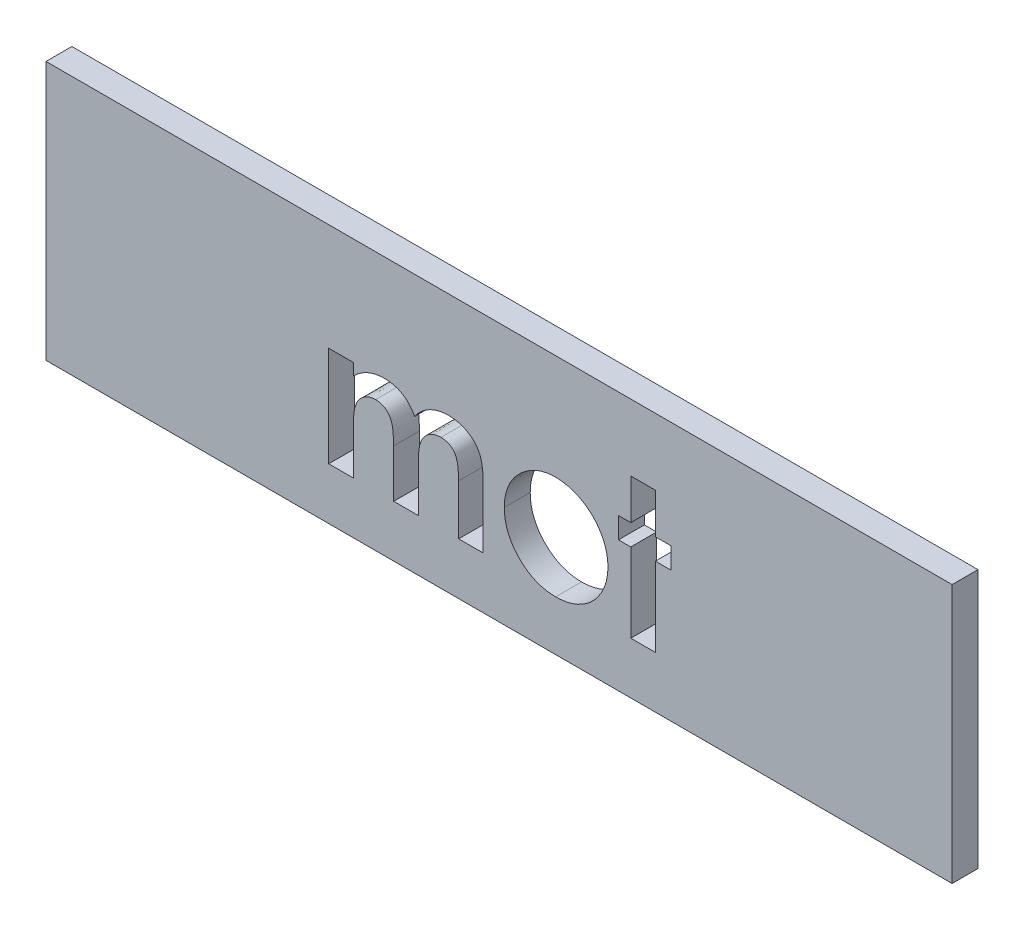
from build123d import *

# Parameters (mm, degrees)
ESQUISSE1_W             = 35
ESQUISSE1_H             = 10
BOSS_EXTRU_1_DEPTH      = 1
ESQUISSE2_R             = 1
BOSS_EXTRU_2_DEPTH      = 3
CHANFREIN1_SIZE         = 0.5
ENL_V_MAT_EXTRU_2_DEPTH = 1


with BuildPart() as part:
    # Esquisse1 → Boss.-Extru.1 (new body)
    with BuildSketch(Plane.XY):
        with Locations((17.5, -5)):
            Rectangle(ESQUISSE1_W, ESQUISSE1_H)
    extrude(amount=BOSS_EXTRU_1_DEPTH)

    # Esquisse2 → Boss.-Extru.2 (add)
    with BuildSketch(Plane(origin=(0, 0, 0), x_dir=(-1, 0, 0), z_dir=(0, 0, -1))):
        with Locations(Location((-30, -5, 0), (0, 0, 180))):  # turned: the seam where the file's is
            Circle(ESQUISSE2_R)
        with Locations(Location((-5, -5, 0), (0, 0, 180))):  # turned: the seam where the file's is
            Circle(ESQUISSE2_R)
    extrude(amount=BOSS_EXTRU_2_DEPTH)

    # Chanfrein1
    chanfrein1_edges = [part.edges().sort_by_distance(p)[0] for p in [
        (29, -5, -3),
        (4, -5, -3),
    ]]
    chamfer(chanfrein1_edges, length=CHANFREIN1_SIZE)

    # Esquisse3 → Enlèv. mat.-Extru.2 (cut)
    with BuildSketch(Plane.XY.offset(1)):
        with BuildLine():
            Line((10.919337607, -4.133012821), (11.869123932, -4.133012821))
            Line((11.869123932, -4.133012821), (11.869123932, -4.59518563))
            add(Edge.make_bspline(
                [(11.869123932, -4.59518563), (11.911369945, -4.552547263), (11.994548872, -4.468595821), (12.132392627, -4.360668696), (12.276177621, -4.268377671), (12.4276463, -4.193662277), (12.586428178, -4.136611678), (12.751770713, -4.09480584), (12.924523171, -4.070141705), (13.042144246, -4.066846229), (13.101938101, -4.06517094)],
                knots=[0, 0, 0, 0, 1.041528618, 2.050684245, 3.032913108, 4.004406485, 4.976926473, 5.95771665, 6.961784757, 8, 8, 8, 8], degree=3))
            add(Edge.make_bspline(
                [(13.101938101, -4.06517094), (13.161810904, -4.067054206), (13.279668581, -4.070761355), (13.451622112, -4.104685241), (13.614520608, -4.159800091), (13.766571805, -4.238359539), (13.908874639, -4.335376374), (14.035125, -4.45586279), (14.148765497, -4.595022486), (14.209340256, -4.700228713), (14.240409655, -4.754190037)],
                knots=[0, 0, 0, 0, 1.023965777, 2.015643508, 2.987309376, 3.958410333, 4.93654923, 5.924956801, 6.93568961, 8, 8, 8, 8], degree=3))
            add(Edge.make_bspline(
                [(14.240409655, -4.754190037), (14.280431057, -4.700081917), (14.358981836, -4.593882862), (14.498220248, -4.455227954), (14.648778513, -4.33536381), (14.813569588, -4.237643293), (14.988217192, -4.160068241), (15.171957089, -4.104890023), (15.363123432, -4.070818051), (15.493222619, -4.067068949), (15.559086205, -4.06517094)],
                knots=[0, 0, 0, 0, 1.041189987, 2.043563759, 3.033412161, 4.015238574, 5.00275396, 5.986226558, 6.980513695, 8, 8, 8, 8], degree=3))
            add(Edge.make_bspline(
                [(15.559086205, -4.06517094), (15.627115467, -4.067141729), (15.759596132, -4.070979658), (15.95157964, -4.108738156), (16.131395426, -4.167080701), (16.295069614, -4.251983383), (16.443069016, -4.352553973), (16.569182361, -4.471382321), (16.673844914, -4.604321999), (16.741993657, -4.728455222), (16.786049989, -4.838203205), (16.812651593, -4.933704514), (16.837532324, -5.040343805), (16.855406639, -5.159554459), (16.872091524, -5.290215988), (16.881777755, -5.433197075), (16.888361587, -5.588016049), (16.889060874, -5.695134454), (16.889423077, -5.750617655)],
                knots=[0, 0, 0, 0, 1.321991808, 2.574456155, 3.791773975, 4.987670122, 6.148905103, 7.262530793, 8.344737981, 9.427709016, 10.004683293, 10.642050061, 11.354108788, 12.133887687, 12.985666279, 13.916212488, 14.92067847, 16, 16, 16, 16], degree=3))
            Line((16.889423077, -5.750617655), (16.889423077, -8))
            Line((16.889423077, -8), (15.939636752, -8))
            Line((15.939636752, -8), (15.939636752, -6.058026175))
            add(Edge.make_bspline(
                [(15.939636752, -6.058026175), (15.938846235, -6.006081985), (15.937328909, -5.906379806), (15.93087817, -5.763376066), (15.916438656, -5.633684014), (15.899513696, -5.516585277), (15.875293753, -5.412700728), (15.845761929, -5.321779938), (15.811505193, -5.243692031), (15.770141216, -5.178445146), (15.723813514, -5.123496962), (15.672280628, -5.076395486), (15.616079868, -5.036208607), (15.554701692, -5.001955004), (15.486538148, -4.978788614), (15.41389033, -4.960611438), (15.336189747, -4.948232651), (15.282467581, -4.947494664), (15.254857772, -4.947115385)],
                knots=[0, 0, 0, 0, 1.669139205, 3.203761885, 4.596586177, 5.860166715, 7.002923539, 8.018877315, 8.928339525, 9.734594377, 10.491888885, 11.231098709, 11.971440889, 12.708030942, 13.480072485, 14.275788656, 15.113863979, 16, 16, 16, 16], degree=3))
            add(Edge.make_bspline(
                [(15.254857772, -4.947115385), (15.212311448, -4.948586321), (15.128822752, -4.951472742), (15.007162706, -4.979055723), (14.892679706, -5.024150945), (14.785802653, -5.085499), (14.688831303, -5.162121562), (14.60400592, -5.253003227), (14.533951983, -5.358667753), (14.48545894, -5.456703237), (14.455156879, -5.545347015), (14.43378153, -5.621263291), (14.417120294, -5.707113371), (14.404079425, -5.802027791), (14.391568234, -5.906543112), (14.385430314, -6.02052717), (14.379149348, -6.143821616), (14.379231113, -6.229033939), (14.379273504, -6.273212139)],
                knots=[0, 0, 0, 0, 1.129913425, 2.217230253, 3.297175357, 4.391411011, 5.481605898, 6.571841268, 7.681894157, 8.841607612, 9.468549532, 10.170608623, 10.93710061, 11.791434153, 12.717934886, 13.734733707, 14.825576123, 16, 16, 16, 16], degree=3))
            Line((14.379273504, -6.273212139), (14.379273504, -8))
            Line((14.379273504, -8), (13.429487179, -8))
            Line((13.429487179, -8), (13.429487179, -6.146008614))
            add(Edge.make_bspline(
                [(13.429487179, -6.146008614), (13.429407435, -6.104662165), (13.429254033, -6.02512499), (13.424643067, -5.910271787), (13.418537248, -5.804220605), (13.409977599, -5.706675648), (13.400105731, -5.617758237), (13.38585835, -5.537954814), (13.370890161, -5.466825637), (13.345227, -5.386025014), (13.309064305, -5.296484401), (13.25503671, -5.201531568), (13.18970997, -5.122030947), (13.114735212, -5.057363855), (13.030010519, -5.00809272), (12.93768223, -4.971441119), (12.835987395, -4.95165771), (12.76598747, -4.948661445), (12.729867788, -4.947115385)],
                knots=[0, 0, 0, 0, 1.256487322, 2.417074606, 3.49288742, 4.484586665, 5.393016842, 6.210437544, 6.947749329, 7.599905853, 8.784490193, 9.876739139, 10.906602197, 11.896672079, 12.869113195, 13.872201355, 14.902064413, 16, 16, 16, 16], degree=3))
            add(Edge.make_bspline(
                [(12.729867788, -4.947115385), (12.689055656, -4.948500619), (12.608226888, -4.951244088), (12.490487438, -4.980711182), (12.377917606, -5.024978991), (12.272993811, -5.088038137), (12.177483341, -5.166463861), (12.09350724, -5.259930578), (12.023821463, -5.36832742), (11.975113169, -5.469067075), (11.945252948, -5.559922392), (11.923302846, -5.637809906), (11.907261515, -5.725550598), (11.893877502, -5.822159294), (11.881440381, -5.927750032), (11.875277064, -6.042787158), (11.869002305, -6.167143162), (11.869082412, -6.253061473), (11.869123932, -6.297592815)],
                knots=[0, 0, 0, 0, 1.07893236, 2.136834559, 3.195274846, 4.273923004, 5.364443877, 6.458052972, 7.587287137, 8.767908, 9.410170275, 10.118584836, 10.909717261, 11.770069756, 12.702352573, 13.724628867, 14.820678298, 16, 16, 16, 16], degree=3))
            Line((11.869123932, -6.297592815), (11.869123932, -8))
            Line((11.869123932, -8), (10.919337607, -8))
            Line((10.919337607, -8), (10.919337607, -4.133012821))
        make_face()
        with BuildLine():
            add(Edge.make_bspline(
                [(19.681540465, -4.06517094), (19.726444529, -4.065970039), (19.815374922, -4.067552616), (19.947825633, -4.080726126), (20.077960801, -4.102219251), (20.206528424, -4.130049096), (20.332334633, -4.169042871), (20.456039265, -4.215809874), (20.578748398, -4.269503864), (20.697416414, -4.333418492), (20.812900602, -4.402739736), (20.922386485, -4.479206755), (21.024964859, -4.562218928), (21.122539926, -4.649851552), (21.210564532, -4.745919865), (21.294663922, -4.845794894), (21.370294409, -4.953054811), (21.440317345, -5.065085941), (21.502658262, -5.18124043), (21.556789883, -5.300710266), (21.603771041, -5.421843694), (21.640556346, -5.546116201), (21.671011188, -5.67188909), (21.690230358, -5.800703613), (21.703893855, -5.931236522), (21.705425966, -6.019122018), (21.706196581, -6.063326322)],
                knots=[0, 0, 0, 0, 1.022364134, 2.024744242, 3.027414945, 4.024939316, 5.017584196, 6.023349371, 7.035562955, 8.064994934, 9.090267829, 10.101425541, 11.102933353, 12.093946398, 13.084502048, 14.067315274, 15.065326281, 16.070028806, 17.074376865, 18.064572984, 19.055292013, 20.030201733, 21.013838017, 21.999348303, 22.993720005, 24, 24, 24, 24], degree=3))
            add(Edge.make_bspline(
                [(21.706196581, -6.063326322), (21.705383324, -6.107875973), (21.703766386, -6.196450777), (21.690724686, -6.328211509), (21.669149293, -6.457631787), (21.641212636, -6.585474047), (21.602364786, -6.710102427), (21.556975221, -6.833353996), (21.501257744, -6.953548791), (21.439657967, -7.071998023), (21.369184813, -7.185216092), (21.293619792, -7.293550495), (21.209872653, -7.394159111), (21.122552708, -7.490162093), (21.027518175, -7.57831305), (20.926285984, -7.660043319), (20.819732523, -7.736352088), (20.707091561, -7.805449009), (20.58980584, -7.866162011), (20.469853363, -7.920899736), (20.346532713, -7.9664728), (20.220099109, -8.003636379), (20.090475874, -8.032411209), (19.957949183, -8.051958292), (19.822804448, -8.065553064), (19.731749247, -8.06707403), (19.685780582, -8.06784188)],
                knots=[0, 0, 0, 0, 1.012026251, 2.012137606, 3.004615893, 3.992048833, 4.982446996, 5.968083444, 6.973977695, 7.990229942, 8.999482246, 10.001782172, 10.988562221, 11.971415814, 12.948383116, 13.930088534, 14.925840678, 15.924049238, 16.929462851, 17.924729459, 18.917889337, 19.913673841, 20.916777188, 21.931792057, 22.95587778, 24, 24, 24, 24], degree=3))
            add(Edge.make_bspline(
                [(19.685780582, -8.06784188), (19.61856502, -8.065868971), (19.486082124, -8.061980337), (19.29096614, -8.03534421), (19.103524089, -7.989496451), (18.923450535, -7.925585687), (18.750511559, -7.843686424), (18.586216434, -7.742323649), (18.428930871, -7.623492905), (18.281379174, -7.488198559), (18.146201831, -7.339768411), (18.028108159, -7.181320132), (17.927837074, -7.015228595), (17.845478791, -6.841304401), (17.781914991, -6.659309053), (17.736011082, -6.469786652), (17.709342389, -6.272204479), (17.705486643, -6.137961452), (17.703525641, -6.069686498)],
                knots=[0, 0, 0, 0, 1.029999031, 2.030143771, 3.011211297, 3.982305373, 4.953580601, 5.938004764, 6.935448627, 7.970290061, 9.001484052, 10.007591832, 10.993831261, 11.969999897, 12.951306496, 13.942897864, 14.953773953, 16, 16, 16, 16], degree=3))
            add(Edge.make_bspline(
                [(17.703525641, -6.069686498), (17.705555029, -5.996783815), (17.709543751, -5.85349505), (17.741215955, -5.643573745), (17.79179305, -5.442584044), (17.864393283, -5.251088178), (17.957133695, -5.068732961), (18.070348721, -4.895902998), (18.204597875, -4.732559142), (18.307405845, -4.633763179), (18.359683827, -4.583525307)],
                knots=[0, 0, 0, 0, 1.043912699, 2.05178951, 3.033892, 4.007821512, 4.978932272, 5.95884105, 6.962068106, 8, 8, 8, 8], degree=3))
            add(Edge.make_bspline(
                [(18.359683827, -4.583525307), (18.407654102, -4.541883762), (18.502289522, -4.459733615), (18.656040934, -4.35553962), (18.81346503, -4.265547797), (18.976448605, -4.19155778), (19.145446017, -4.135770502), (19.31959125, -4.095162354), (19.498848091, -4.07021964), (19.620333533, -4.066862392), (19.681540465, -4.06517094)],
                knots=[0, 0, 0, 0, 1.048115528, 2.067714963, 3.060638214, 4.039924844, 5.017819947, 5.994373833, 6.98952318, 8, 8, 8, 8], degree=3))
        make_face()
        with BuildLine():
            add(Edge.make_bspline(
                [(19.702741052, -4.947115385), (19.665967932, -4.948337601), (19.59357965, -4.950743548), (19.487022196, -4.963655622), (19.386239033, -4.990120026), (19.289228422, -5.023775504), (19.197706488, -5.068784965), (19.109166771, -5.121456407), (19.028213143, -5.187368235), (18.950927999, -5.259668688), (18.880770315, -5.339956401), (18.820989306, -5.427429804), (18.76757365, -5.518742348), (18.727071267, -5.6172371), (18.693551673, -5.720221911), (18.670866013, -5.829360703), (18.655078379, -5.943434337), (18.653906371, -6.021575558), (18.653311966, -6.061206263)],
                knots=[0, 0, 0, 0, 1.030650113, 2.02884584, 2.99876339, 3.944280128, 4.900564847, 5.851248946, 6.823638398, 7.81794922, 8.81432732, 9.802856497, 10.78262424, 11.771747962, 12.779760563, 13.812642396, 14.89064281, 16, 16, 16, 16], degree=3))
            add(Edge.make_bspline(
                [(18.653311966, -6.061206263), (18.6540075, -6.102234547), (18.655366789, -6.182416449), (18.669442504, -6.299492807), (18.692653823, -6.410597496), (18.725629832, -6.515558881), (18.767102732, -6.615130364), (18.817985171, -6.708753279), (18.878814156, -6.79586471), (18.947779461, -6.876357385), (19.023293524, -6.949421477), (19.106035932, -7.012122346), (19.192541742, -7.06660108), (19.284804519, -7.110355912), (19.381513867, -7.144138192), (19.482956876, -7.169010948), (19.589666628, -7.182411184), (19.662425816, -7.184719372), (19.699560964, -7.185897436)],
                knots=[0, 0, 0, 0, 1.141730614, 2.231293227, 3.276944405, 4.297399982, 5.28939179, 6.275415646, 7.257752684, 8.24146775, 9.222424823, 10.176631434, 11.126518621, 12.063689483, 13.012557477, 13.974037417, 14.965980454, 16, 16, 16, 16], degree=3))
            add(Edge.make_bspline(
                [(19.699560964, -7.185897436), (19.736714686, -7.184852547), (19.809557549, -7.182803958), (19.916392612, -7.167463261), (20.018353664, -7.143320027), (20.115888985, -7.109246995), (20.208209994, -7.064555614), (20.295670104, -7.009816247), (20.379038713, -6.946243265), (20.455566182, -6.871800593), (20.526406197, -6.79105689), (20.588528653, -6.703485604), (20.640440521, -6.609862664), (20.683017547, -6.510777147), (20.716058201, -6.406365245), (20.738885252, -6.296238872), (20.754681327, -6.180739318), (20.755826829, -6.101542694), (20.756410256, -6.061206263)],
                knots=[0, 0, 0, 0, 1.031504075, 2.022346795, 2.991027682, 3.937587355, 4.885570121, 5.833146507, 6.798790848, 7.791235734, 8.792807298, 9.778388351, 10.766749885, 11.760164525, 12.768777521, 13.802286646, 14.880660483, 16, 16, 16, 16], degree=3))
            add(Edge.make_bspline(
                [(20.756410256, -6.061206263), (20.755705874, -6.020883931), (20.754323647, -5.941758434), (20.740246929, -5.826102668), (20.717263399, -5.716332255), (20.683862072, -5.612915903), (20.642635681, -5.514673798), (20.591718073, -5.422108802), (20.530589098, -5.335676824), (20.461288534, -5.255806439), (20.384642467, -5.183767603), (20.303336668, -5.119526449), (20.215511922, -5.066394079), (20.122815874, -5.022594039), (20.025001904, -4.988896161), (19.922179826, -4.963882444), (19.81403452, -4.950672888), (19.740226592, -4.948313613), (19.702741052, -4.947115385)],
                knots=[0, 0, 0, 0, 1.123894411, 2.205445421, 3.243160173, 4.246488011, 5.231014757, 6.210004299, 7.185865357, 8.177612767, 9.153374344, 10.115157457, 11.061423229, 12.009021698, 12.96873347, 13.94135618, 14.954456845, 16, 16, 16, 16], degree=3))
        make_face(mode=Mode.SUBTRACT)
        Polygon((22.588141026, -2.572649573), (23.53792735, -2.572649573), (23.53792735, -4.133012821), (24.148504274, -4.133012821), (24.148504274, -4.947115385), (23.53792735, -4.947115385), (23.53792735, -8), (22.588141026, -8), (22.588141026, -4.947115385), (22.113247863, -4.947115385), (22.113247863, -4.133012821), (22.588141026, -4.133012821), align=None)
    extrude(amount=-ENL_V_MAT_EXTRU_2_DEPTH, mode=Mode.SUBTRACT)


with BuildPart() as body_2:
    # of the pieces the cut leaves, the one that is kept (enl_v_mat_extru_2_keep)
    add(part.part.solids().sort_by_distance((31, -5, -2.5))[0])


solid = body_2.part
